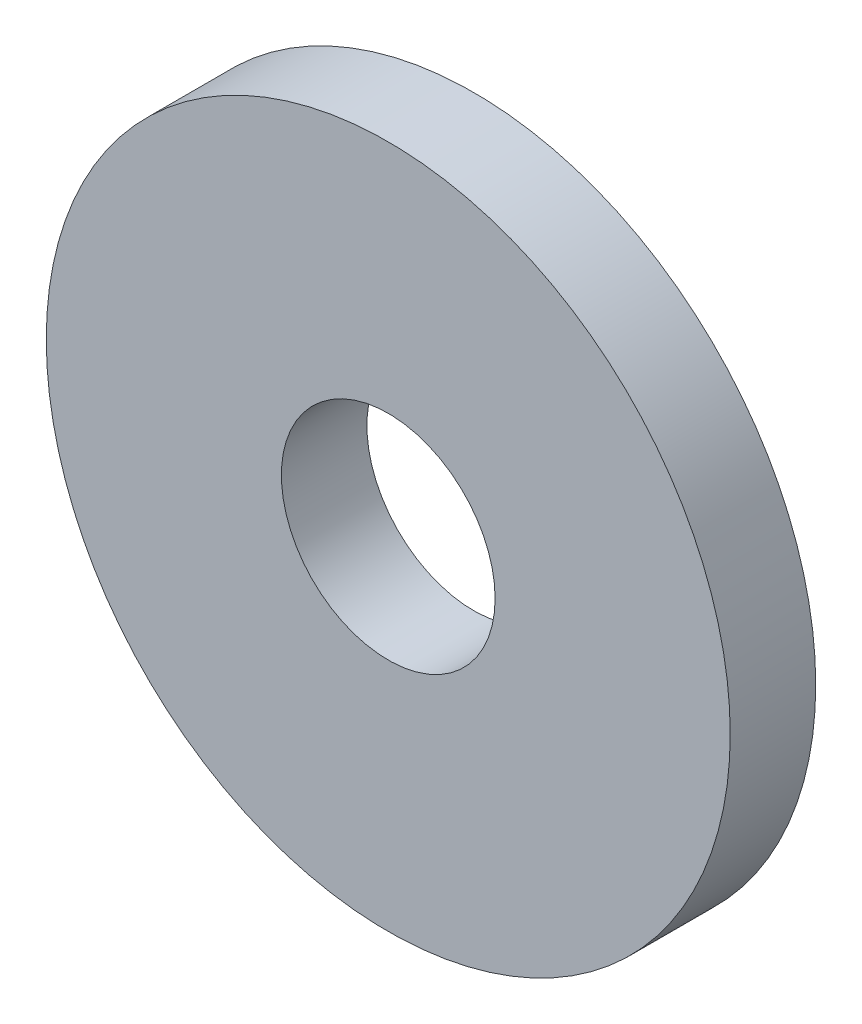
from build123d import *

# Parameters (mm, degrees)
SKETCH1_R           = 8
SKETCH1_R_2         = 2.5
BOSS_EXTRUDE1_DEPTH = 2


with BuildPart() as part:
    # Sketch1 → Boss-Extrude1 (new body)
    with BuildSketch(Plane.XY):
        Circle(SKETCH1_R)
        Circle(SKETCH1_R_2, mode=Mode.SUBTRACT)
    extrude(amount=BOSS_EXTRUDE1_DEPTH)


solid = part.part
